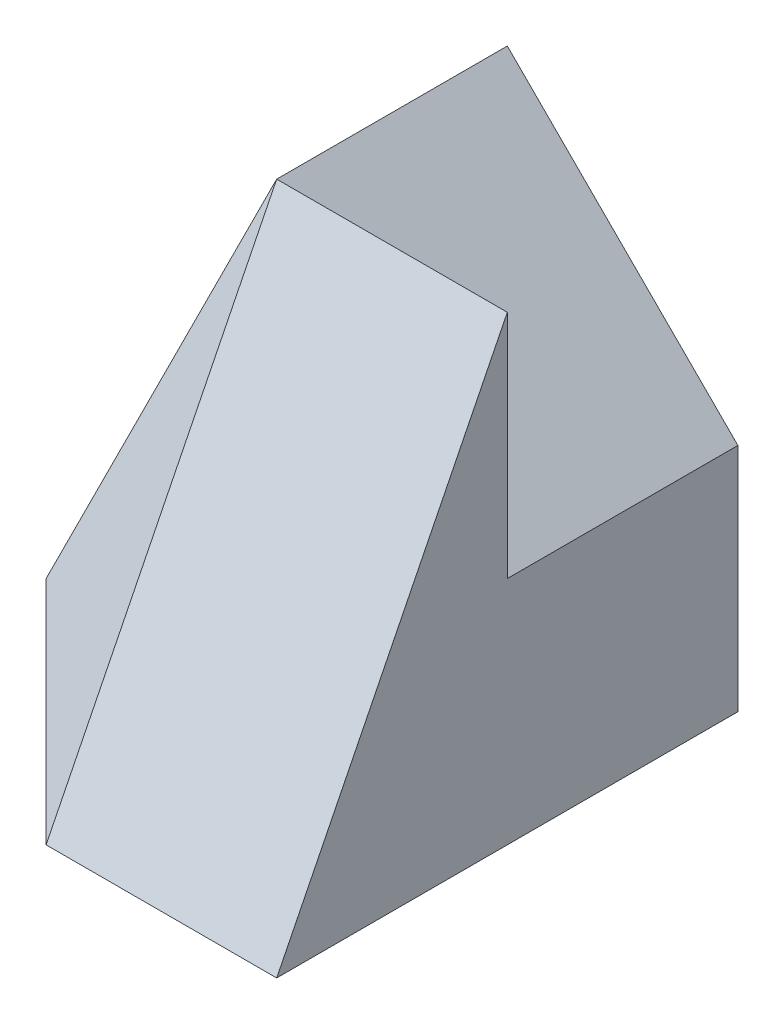
from build123d import *

# Parameters (mm, degrees)
SKETCH1_W           = 20
SKETCH1_H           = 40
BOSS_EXTRUDE1_DEPTH = 40
BOSS_EXTRUDE2_DEPTH = 20
CUT_EXTRUDE1_DEPTH  = 20
CUT_EXTRUDE2_DEPTH  = 20
BOSS_EXTRUDE3_DEPTH = 20
SKETCH6_W           = 20
SKETCH6_H           = 28.284271247
CUT_EXTRUDE3_DEPTH  = 20
SKETCH7_W           = 40
SKETCH7_H           = 40
CUT_EXTRUDE4_DEPTH  = 20


with BuildPart() as part:
    # Sketch1 → Boss-Extrude1 (new body)
    with BuildSketch(Plane.XY):
        with Locations((10, 20)):
            Rectangle(SKETCH1_W, SKETCH1_H)
    extrude(amount=BOSS_EXTRUDE1_DEPTH)

    # Sketch2 → Boss-Extrude2 (add)
    with BuildSketch(Plane(origin=(0, 0, 0), x_dir=(-1, 0, 0), z_dir=(0, 0, -1))):
        Polygon((0, 0), (20, 0), (0, 40), align=None)
    extrude(amount=-BOSS_EXTRUDE2_DEPTH)

    # Sketch3 → Cut-Extrude1 (cut)
    with BuildSketch(Plane(origin=(0, 0, 0), x_dir=(-1, 0, 0), z_dir=(0, 0, -1))):
        Polygon((0, 40), (-20, 20), (-20, 40), align=None)
    extrude(amount=-CUT_EXTRUDE1_DEPTH, mode=Mode.SUBTRACT)

    # Sketch4 → Cut-Extrude2 (cut)
    with BuildSketch(Plane.ZY):
        Polygon((20, 40), (40, 0), (40, 40), align=None)
    extrude(amount=-CUT_EXTRUDE2_DEPTH, mode=Mode.SUBTRACT)

    # Sketch5 → Boss-Extrude3 (add)
    with BuildSketch(Plane(origin=(-17.777777778, 8.888888889, 17.777777778), x_dir=(-0.745355992, -0.298142397, -0.596284794), z_dir=(0.666666667, -0.333333333, -0.666666667))):
        Polygon((-23.85139176, 26.83281573), (2.98142397, -8.94427191), (-23.85139176, -17.88854382), align=None)
    extrude(amount=BOSS_EXTRUDE3_DEPTH)

    # Sketch6 → Cut-Extrude3 (cut)
    with BuildSketch(Plane(origin=(20, 20, 0), x_dir=(0, 0, -1), z_dir=(0.707106781, 0.707106781, 0))):
        with Locations((-10, 14.142135624)):
            Rectangle(SKETCH6_W, SKETCH6_H)
    extrude(amount=CUT_EXTRUDE3_DEPTH, mode=Mode.SUBTRACT)

    # Sketch7 → Cut-Extrude4 (cut)
    with BuildSketch(Plane.XZ):
        with Locations((0, 20)):
            Rectangle(SKETCH7_W, SKETCH7_H)
    extrude(amount=CUT_EXTRUDE4_DEPTH, mode=Mode.SUBTRACT)


solid = part.part
